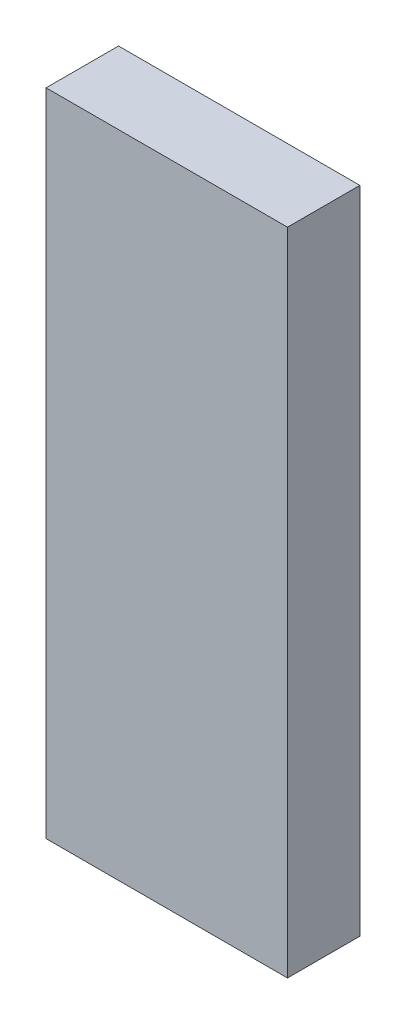
from build123d import *

# Parameters (mm, degrees)
ESQUISSE1_W        = 10
ESQUISSE1_H        = 26.94
BOSS_EXTRU_1_DEPTH = 3


with BuildPart() as part:
    # Esquisse1 → Boss.-Extru.1 (new body)
    with BuildSketch(Plane.XY):
        with Locations((-86.952618127, 46.806649746)):
            Rectangle(ESQUISSE1_W, ESQUISSE1_H)
    extrude(amount=BOSS_EXTRU_1_DEPTH)


solid = part.part
